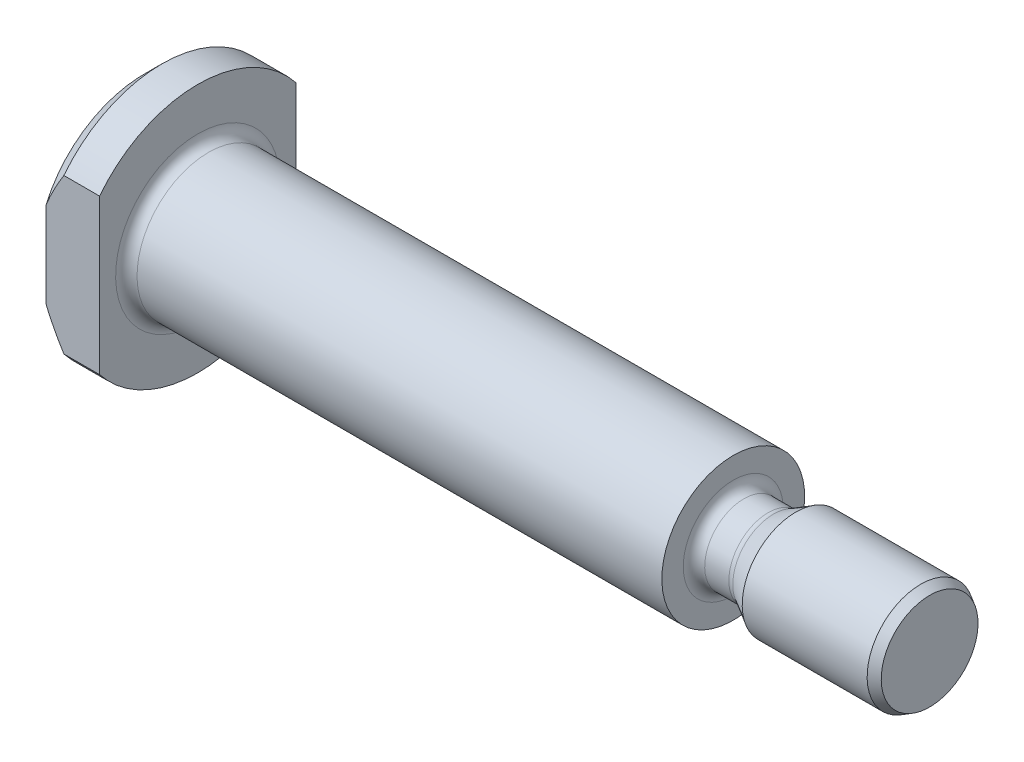
from build123d import *

# Parameters (mm, degrees)
SKIZZE3_W                       = 1.5
SKIZZE3_H                       = 14
SCHNITT_LINEAR_AUSTRAGEN2_DEPTH = 3
VERRUNDUNG1_R                   = 0.6
VERRUNDUNG3_R                   = 0.6


with BuildPart() as part:
    # Skizze1 → Rotation1 (revolve)
    with BuildSketch(Plane.XY):
        Polygon((-3, 0), (-3, 6), (-2, 7), (0, 7), (0, 4), (30, 4), (30, 2.2), (32.114359354, 2.2), (33.5, 3), (40.5, 3), (41, 2.711324865), (41, 0), align=None)
    revolve(axis=Axis((41, 0, 0), (-1, 0, 0)))

    # Skizze3 → Schnitt-Linear austragen2 (cut)
    with BuildSketch(Plane(origin=(0, 0, 0), x_dir=(0, 0, -1), z_dir=(1, 0, 0))):
        with Locations((-6.25, 0)):
            Rectangle(SKIZZE3_W, SKIZZE3_H)
        with Locations((6.25, 0)):
            Rectangle(SKIZZE3_W, SKIZZE3_H)
    extrude(amount=-SCHNITT_LINEAR_AUSTRAGEN2_DEPTH, mode=Mode.SUBTRACT)

    # Verrundung1
    verrundung1_edges = [part.edges().sort_by_distance(p)[0] for p in [
        (0, -4, 0),
    ]]
    fillet(verrundung1_edges, radius=VERRUNDUNG1_R)

    # Verrundung3
    verrundung3_edges = [part.edges().sort_by_distance(p)[0] for p in [
        (32.114359354, -2.2, 0),
        (30, -2.2, 0),
    ]]
    fillet(verrundung3_edges, radius=VERRUNDUNG3_R)


solid = part.part
